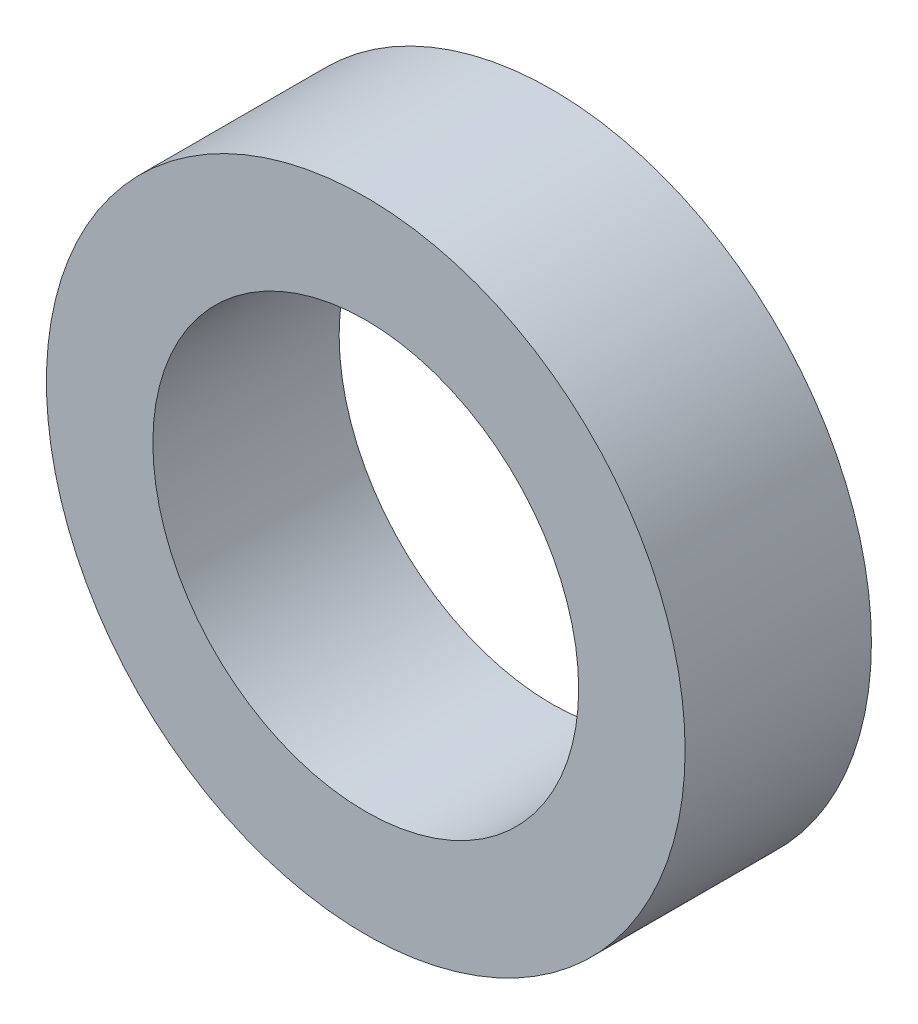
from build123d import *

# Parameters (mm, degrees)
ESQUISSE1_R        = 6
ESQUISSE1_R_2      = 4
BOSS_EXTRU_1_DEPTH = 3.5


with BuildPart() as part:
    # Esquisse1 → Boss.-Extru.1 (new body)
    with BuildSketch(Plane.XY):
        Circle(ESQUISSE1_R)
        Circle(ESQUISSE1_R_2, mode=Mode.SUBTRACT)
    extrude(amount=BOSS_EXTRU_1_DEPTH)


solid = part.part
